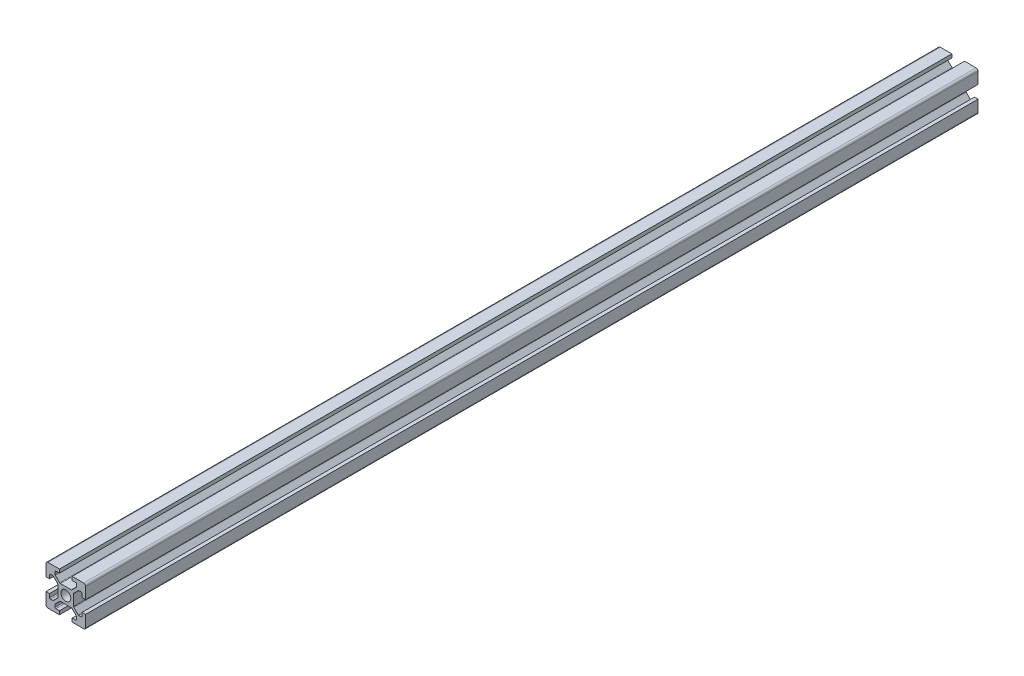
from build123d import *

# Parameters (mm, degrees)
SKETCH1_R           = 2.5
BOSS_EXTRUDE1_DEPTH = 450
FILLET1_R           = 1
FILLET2_R           = 0.5
FILLET3_R           = 0.5
FILLET4_R           = 0.5
FILLET5_R           = 0.5


with BuildPart() as part:
    # Sketch1 → Boss-Extrude1 (new body)
    with BuildSketch(Plane.XY):
        Polygon((13.2, 0), (13.2, 1.8), (15.45, 1.8), (15.45, 3.6), (12.95, 6.1), (7.05, 6.1), (4.55, 3.6), (4.55, 1.8), (6.8, 1.8), (6.8, 0), (0, 0), (0, 6.8), (1.8, 6.8), (1.8, 4.55), (3.6, 4.55), (6.1, 7.05), (6.1, 12.95), (3.6, 15.45), (1.8, 15.45), (1.8, 13.2), (0, 13.2), (0, 20), (6.8, 20), (6.8, 18.2), (4.55, 18.2), (4.55, 16.4), (7.05, 13.9), (12.95, 13.9), (15.45, 16.4), (15.45, 18.2), (13.2, 18.2), (13.2, 20), (20, 20), (20, 13.2), (18.2, 13.2), (18.2, 15.45), (16.4, 15.45), (13.9, 12.95), (13.9, 7.05), (16.4, 4.55), (18.2, 4.55), (18.2, 6.8), (20, 6.8), (20, 0), align=None)
        with Locations((10, 10)):
            Circle(SKETCH1_R, mode=Mode.SUBTRACT)
    extrude(amount=BOSS_EXTRUDE1_DEPTH)

    # Fillet1
    fillet1_edges = [part.edges().sort_by_distance(p)[0] for p in [
        (0, 0, 225),
        (0, 20, 225),
        (20, 20, 225),
        (20, 0, 225),
    ]]
    fillet(fillet1_edges, radius=FILLET1_R)

    # Fillet2
    fillet2_edges = [part.edges().sort_by_distance(p)[0] for p in [
        (4.55, 18.2, 225),
        (4.55, 16.4, 225),
        (7.05, 13.9, 225),
        (12.95, 13.9, 225),
        (15.45, 16.4, 225),
        (15.45, 18.2, 225),
    ]]
    fillet(fillet2_edges, radius=FILLET2_R)

    # Fillet3
    fillet3_edges = [part.edges().sort_by_distance(p)[0] for p in [
        (18.2, 15.45, 225),
        (16.4, 15.45, 225),
        (13.9, 12.95, 225),
        (13.9, 7.05, 225),
        (16.4, 4.55, 225),
        (18.2, 4.55, 225),
    ]]
    fillet(fillet3_edges, radius=FILLET3_R)

    # Fillet4
    fillet4_edges = [part.edges().sort_by_distance(p)[0] for p in [
        (1.8, 4.55, 225),
        (3.6, 4.55, 225),
        (6.1, 7.05, 225),
        (6.1, 12.95, 225),
        (3.6, 15.45, 225),
        (1.8, 15.45, 225),
    ]]
    fillet(fillet4_edges, radius=FILLET4_R)

    # Fillet5
    fillet5_edges = [part.edges().sort_by_distance(p)[0] for p in [
        (15.45, 1.8, 225),
        (15.45, 3.6, 225),
        (12.95, 6.1, 225),
        (7.05, 6.1, 225),
        (4.55, 3.6, 225),
        (4.55, 1.8, 225),
    ]]
    fillet(fillet5_edges, radius=FILLET5_R)


solid = part.part
